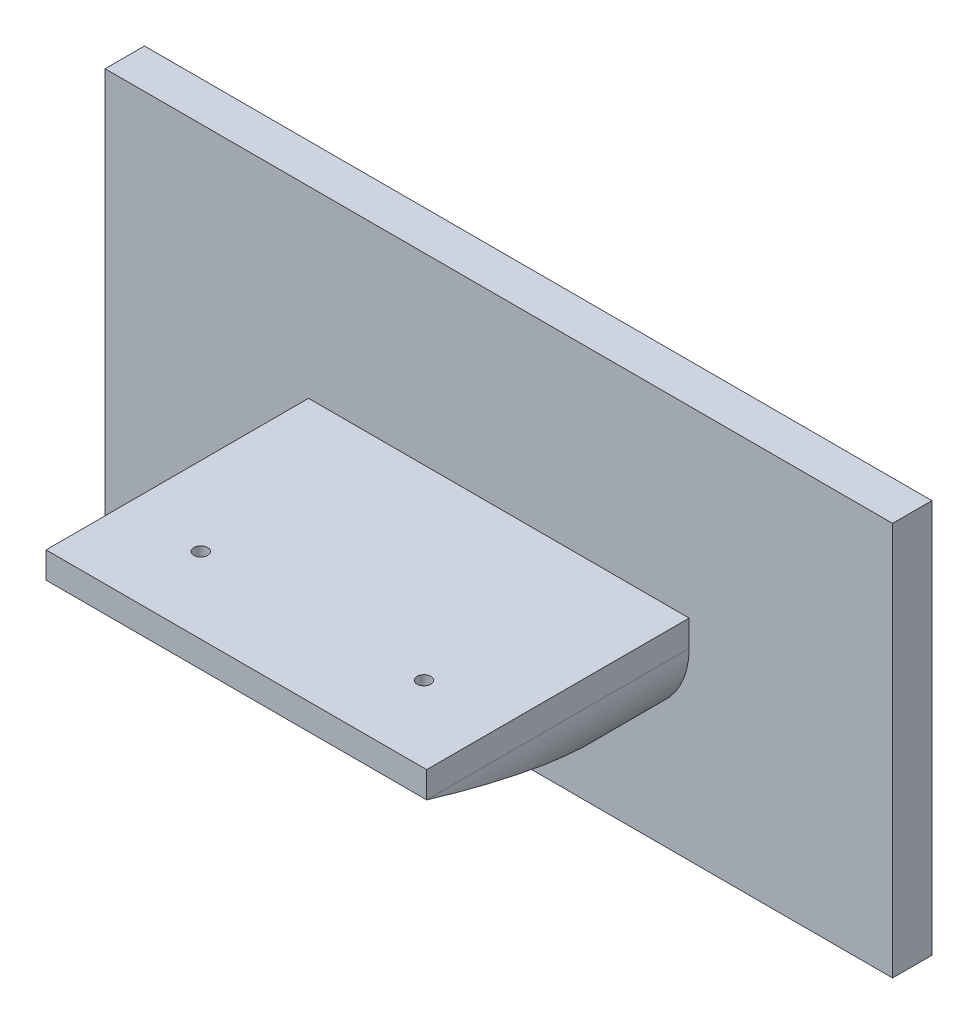
from build123d import *

# Parameters (mm, degrees)
SKETCH1_W                       = 300
SKETCH1_H                       = 150
BOSS_EXTRUDE1_DEPTH             = 15
BOSS_EXTRUDE2_DEPTH             = 100
CUT_EXTRUDE1_DEPTH              = 301
F_5_0_2055_DIAMETER_HOLE1_D     = 5.2197
F_5_0_2055_DIAMETER_HOLE1_DEPTH = 25
F_5_0_2055_DIAMETER_HOLE1_TIP   = 1.568156087


with BuildPart() as part:
    # Sketch1 → Boss-Extrude1 (new body)
    with BuildSketch(Plane.XY):
        with Locations((150, 75)):
            Rectangle(SKETCH1_W, SKETCH1_H)
    extrude(amount=BOSS_EXTRUDE1_DEPTH)

    # Sketch2 → Boss-Extrude2 (add)
    with BuildSketch(Plane.XY.offset(15)):
        with BuildLine():
            Line((77.5, 80), (222.5, 80))
            Line((222.5, 80), (222.5, 70))
            ThreePointArc((222.5, 70), (213.713203436, 48.786796564), (192.5, 40))
            Line((192.5, 40), (107.5, 40))
            ThreePointArc((107.5, 40), (86.286796564, 48.786796564), (77.5, 70))
            Line((77.5, 70), (77.5, 80))
        make_face()
    extrude(amount=BOSS_EXTRUDE2_DEPTH)

    # Sketch3 → Cut-Extrude1 (cut, through all)
    with BuildSketch(Plane(origin=(0, 0, 0), x_dir=(0, 0, -1), z_dir=(1, 0, 0))):
        Polygon((-115, 70), (-15, 40), (-115, 40), align=None)
    extrude(amount=CUT_EXTRUDE1_DEPTH, mode=Mode.SUBTRACT)

    # #5 (0.2055) Diameter Hole1
    with Locations(Plane(origin=(0, 80, 0), x_dir=(1, 0, 0), z_dir=(0, 1, 0))):
        with Locations((107.5, -86.041301647), (192.5, -86.041301647)):
            Hole(F_5_0_2055_DIAMETER_HOLE1_D / 2, depth=F_5_0_2055_DIAMETER_HOLE1_DEPTH)
            with Locations((0, 0, -(F_5_0_2055_DIAMETER_HOLE1_DEPTH + F_5_0_2055_DIAMETER_HOLE1_TIP / 2))):  # 118° drill point
                Cone(0, F_5_0_2055_DIAMETER_HOLE1_D / 2, F_5_0_2055_DIAMETER_HOLE1_TIP, mode=Mode.SUBTRACT)


solid = part.part
